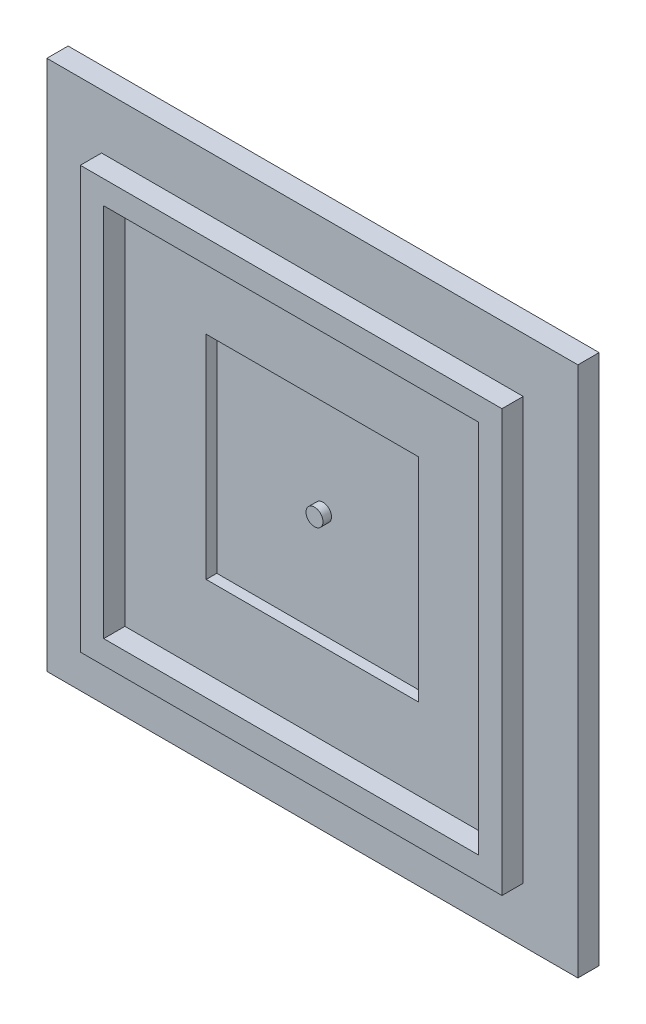
from build123d import *

# Parameters (mm, degrees)
SKETCH1_W            = 127
SKETCH1_H            = 127
BOSS_EXTRUDE1_DEPTH  = 5.08
SKETCH2_W            = 100.838
SKETCH2_H            = 100.838
BOSS_EXTRUDE2_DEPTH  = 5.08
SKETCH3_W            = 89.662
SKETCH3_H            = 89.662
CUT_EXTRUDE1_DEPTH   = 5.08
SKETCH8_W            = 50.8
SKETCH8_H            = 50.8
CUT_EXTRUDE2_DEPTH   = 2.54
SKETCH9_R            = 2.032
BOSS_EXTRUDE10_DEPTH = 2.032


with BuildPart() as part:
    # Sketch1 → Boss-Extrude1 (new body)
    with BuildSketch(Plane.XY):
        Rectangle(SKETCH1_W, SKETCH1_H)
    extrude(amount=-BOSS_EXTRUDE1_DEPTH)

    # Sketch2 → Boss-Extrude2 (add)
    with BuildSketch(Plane.XY):
        Rectangle(SKETCH2_W, SKETCH2_H)
    extrude(amount=BOSS_EXTRUDE2_DEPTH)

    # Sketch3 → Cut-Extrude1 (cut)
    with BuildSketch(Plane.XY.offset(5.08)):
        Rectangle(SKETCH3_W, SKETCH3_H)
    extrude(amount=-CUT_EXTRUDE1_DEPTH, mode=Mode.SUBTRACT)

    # Sketch8 → Cut-Extrude2 (cut)
    with BuildSketch(Plane.XY):
        Rectangle(SKETCH8_W, SKETCH8_H)
    extrude(amount=-CUT_EXTRUDE2_DEPTH, mode=Mode.SUBTRACT)

    # Sketch9 → Boss-Extrude10 (add)
    with BuildSketch(Plane.XY.offset(-2.54)):
        Circle(SKETCH9_R)
    extrude(amount=BOSS_EXTRUDE10_DEPTH)


solid = part.part
